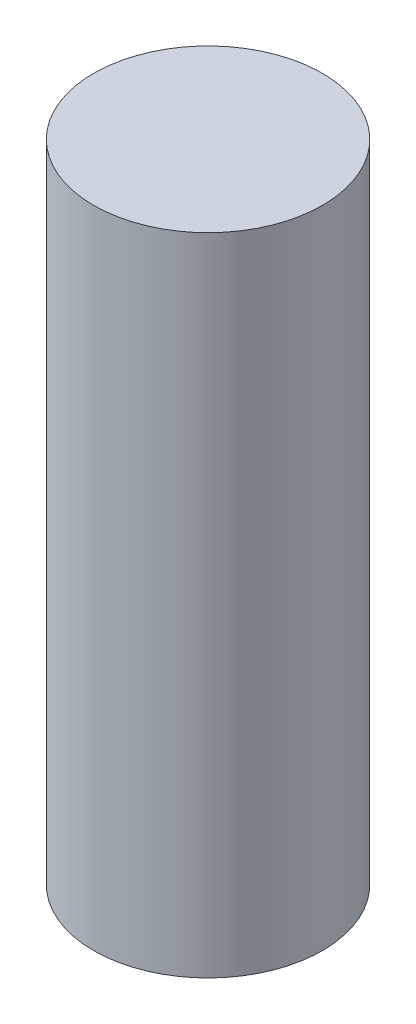
from build123d import *

# Parameters (mm, degrees)
SKETCH_1_R      = 5
EXTRUDE_1_DEPTH = 28.213538


with BuildPart() as part:
    # Эскиз1 → Бобышка-Вытянуть1 (new body)
    with BuildSketch(Plane(origin=(0, 0, 0), x_dir=(1, 0, 0), z_dir=(0, 1, 0))):
        Circle(SKETCH_1_R)
    extrude(amount=EXTRUDE_1_DEPTH)


solid = part.part
